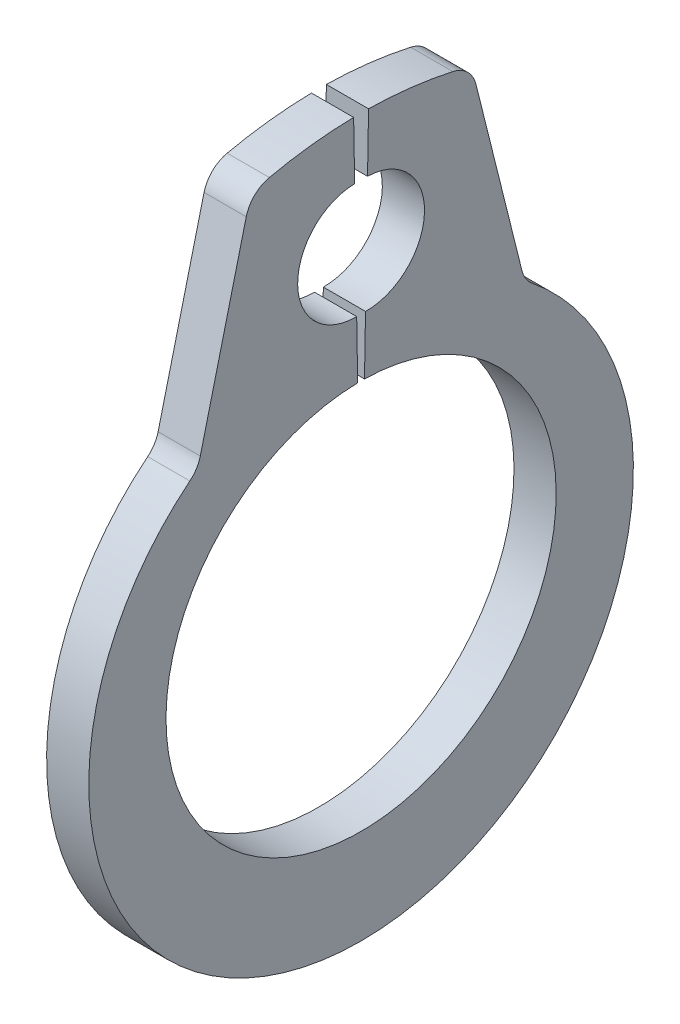
from build123d import *

# Parameters (mm, degrees)
EXTRUDE1_DEPTH = 0.2
FILLET1_R      = 0.29


with BuildPart() as part:
    # Sketch1 → Extrude1 (new body, symmetric)
    with BuildSketch(Plane(origin=(0, 0, 0), x_dir=(0, 0, -1), z_dir=(1, 0, 0))):
        with BuildLine():
            Line((0.032286952, 1.849718236), (0.041885775, 2.399634468))
            ThreePointArc((0.041885775, 2.399634468), (0.601400831, 2.939951877), (0.061083423, 3.499466933))
            Line((0.061083423, 3.499466933), (0.070682246, 4.049383165))
            ThreePointArc((0.070682246, 4.049383165), (0.562907746, 4.010690074), (1.046766998, 3.912387871))
            Line((1.046766998, 3.912387871), (1.548955628, 1.898219287))
            ThreePointArc((1.548955628, 1.898219287), (0, -2.75), (-1.548955628, 1.898219287))
            Line((-1.548955628, 1.898219287), (-1.046766998, 3.912387871))
            ThreePointArc((-1.046766998, 3.912387871), (-0.562907746, 4.010690074), (-0.070682246, 4.049383165))
            Line((-0.070682246, 4.049383165), (-0.061083423, 3.499466933))
            ThreePointArc((-0.061083423, 3.499466933), (-0.601400831, 2.939951877), (-0.041885775, 2.399634468))
            Line((-0.041885775, 2.399634468), (-0.032286952, 1.849718236))
            ThreePointArc((-0.032286952, 1.849718236), (0, -1.85), (0.032286952, 1.849718236))
        make_face()
    extrude(amount=EXTRUDE1_DEPTH, both=True)

    # Fillet1
    fillet1_edges = [part.edges().sort_by_distance(p)[0] for p in [
        (0, 3.912387871, -1.046766998),
        (0, 1.898219287, -1.548955628),
        (0, 1.898219287, 1.548955628),
        (0, 3.912387871, 1.046766998),
    ]]
    fillet(fillet1_edges, radius=FILLET1_R)


solid = part.part
